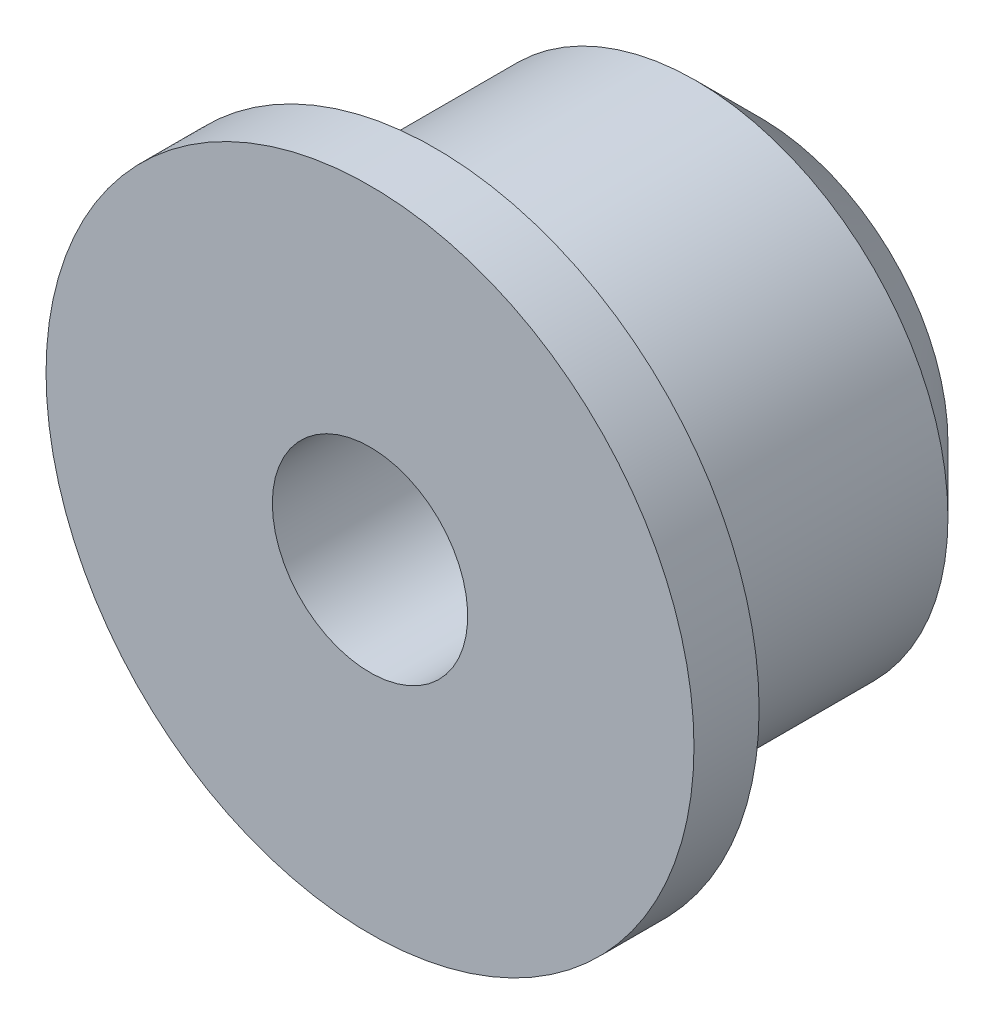
from build123d import *

# Parameters (mm, degrees)
SKETCH1_R           = 7.75
SKETCH1_R_2         = 2.5
BOSS_EXTRUDE1_DEPTH = 12
SKETCH2_R           = 9.95
SKETCH2_R_2         = 3
BOSS_EXTRUDE2_DEPTH = 2
CHAMFER1_SIZE       = 2
SKETCH3_R           = 3
CUT_EXTRUDE1_DEPTH  = 13


with BuildPart() as part:
    # Sketch1 → Boss-Extrude1 (new body)
    with BuildSketch(Plane.XY):
        Circle(SKETCH1_R)
        Circle(SKETCH1_R_2, mode=Mode.SUBTRACT)
    extrude(amount=BOSS_EXTRUDE1_DEPTH)

    # Sketch2 → Boss-Extrude2 (add)
    with BuildSketch(Plane.XY.offset(12)):
        Circle(SKETCH2_R)
        Circle(SKETCH2_R_2, mode=Mode.SUBTRACT)
    extrude(amount=-BOSS_EXTRUDE2_DEPTH)

    # Chamfer1
    chamfer1_edges = [part.edges().sort_by_distance(p)[0] for p in [
        (-7.75, 0, 0),
    ]]
    chamfer(chamfer1_edges, length=CHAMFER1_SIZE)

    # Sketch3 → Cut-Extrude1 (cut, through all)
    with BuildSketch(Plane(origin=(0, 0, 0), x_dir=(-1, 0, 0), z_dir=(0, 0, -1))):
        Circle(SKETCH3_R)
    extrude(amount=-CUT_EXTRUDE1_DEPTH, mode=Mode.SUBTRACT)


solid = part.part
